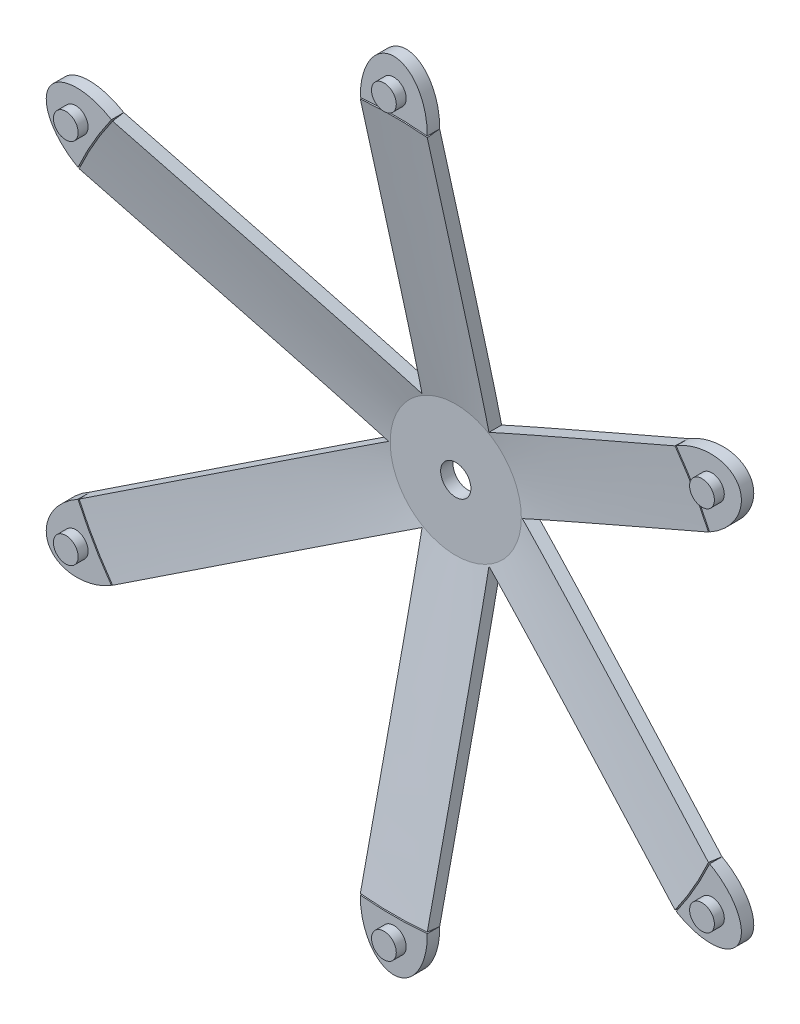
from build123d import *

# Parameters (mm, degrees)
F_6_1_6_1_DIAMETER_HOLE1_D = 6.1
CUT_EXTRUDE6_DEPTH         = 16
BOSS_EXTRUDE1_DEPTH        = 2.5
BOSS_EXTRUDE1_2_DEPTH      = 2.5
BOSS_EXTRUDE1_3_DEPTH      = 2.5
BOSS_EXTRUDE1_4_DEPTH      = 2.5
BOSS_EXTRUDE1_5_DEPTH      = 2.5
BOSS_EXTRUDE1_6_DEPTH      = 2.5
SKETCH8_R                  = 2.5
BOSS_EXTRUDE2_DEPTH        = 2


with BuildPart() as part:
    # Sketch1 → Revolve1 (revolve)
    with BuildSketch(Plane(origin=(0, 0, 0), x_dir=(1, 0, 0), z_dir=(0, 1, 0))):
        Polygon((0, 15), (13.5, 15), (70, 2.5), (69.726754993, 0), (13.226754993, 12.5), (0, 12.5), align=None)
    revolve(axis=Axis((0, 0, -12.5), (0, 0, -1)))

    # Ø6.1 (6.1) Diameter Hole1 (through all)
    with Locations(Plane(origin=(0, 0, -15), x_dir=(-1, 0, 0), z_dir=(0, 0, -1))):
        with Locations((0, 0)):
            Hole(F_6_1_6_1_DIAMETER_HOLE1_D / 2)

    # Sketch6 → Cut-Extrude6 (cut, through all)
    with BuildSketch(Plane.XY):
        with BuildLine():
            Line((6.75, 11.691342951), (6.75, 69.673793495))
            ThreePointArc((6.75, 69.673793495), (35, 60.621778265), (56.964275145, 40.682568223))
            Line((56.964275145, 40.682568223), (6.75, 11.691342951))
        make_face()
        with BuildLine():
            Line((13.5, 0), (63.714275145, 28.991225272))
            ThreePointArc((63.714275145, 28.991225272), (69.046745107, 11.512905374), (69.673793495, -6.75))
            ThreePointArc((69.673793495, -6.75), (67.61480784, -18.117333157), (63.714275145, -28.991225272))
            Line((63.714275145, -28.991225272), (13.5, 0))
        make_face()
        with BuildLine():
            Line((-6.75, 11.691342951), (-6.75, 69.673793495))
            ThreePointArc((-6.75, 69.673793495), (-35, 60.621778265), (-56.964275145, 40.682568223))
            Line((-56.964275145, 40.682568223), (-6.75, 11.691342951))
        make_face()
        with BuildLine():
            Line((6.75, -11.691342951), (56.964275145, -40.682568223))
            ThreePointArc((56.964275145, -40.682568223), (35, -60.621778265), (6.75, -69.673793495))
            Line((6.75, -69.673793495), (6.75, -11.691342951))
        make_face()
        with BuildLine():
            Line((-6.75, -11.691342951), (-6.75, -69.673793495))
            ThreePointArc((-6.75, -69.673793495), (-35, -60.621778265), (-56.964275145, -40.682568223))
            Line((-56.964275145, -40.682568223), (-6.75, -11.691342951))
        make_face()
        with BuildLine():
            Line((-13.5, 0), (-63.714275145, -28.991225272))
            ThreePointArc((-63.714275145, -28.991225272), (-67.61480784, -18.117333157), (-69.673793495, -6.75))
            ThreePointArc((-69.673793495, -6.75), (-69.046745107, 11.512905374), (-63.714275145, 28.991225272))
            Line((-63.714275145, 28.991225272), (-13.5, 0))
        make_face()
    extrude(amount=-CUT_EXTRUDE6_DEPTH, mode=Mode.SUBTRACT)


with BuildPart() as body_2:
    # Sketch7 → Boss-Extrude1 (new body)
    with BuildSketch(Plane.XY):
        with BuildLine():
            ThreePointArc((6.746587752, 69.67412399), (0, 70), (-6.746587752, 69.67412399))
            add(Edge.make_bspline(
                [(6.746587752, 69.67412399), (6.968123789, 80.25), (0, 80.25), (-6.968123789, 80.25), (-6.746587752, 69.67412399)],
                knots=[1.538998187, 1.538998187, 1.538998187, 3.141592654, 3.141592654, 4.74418712, 4.74418712, 4.74418712], degree=2, weights=[1, 0.695775545, 1, 0.695775545, 1]))
        make_face()
    extrude(amount=-BOSS_EXTRUDE1_DEPTH)



with BuildPart() as body_3:
    # Sketch7 → Boss-Extrude1 2 (new body)
    with BuildSketch(Plane.XY):
        with BuildLine():
            ThreePointArc((63.712855237, 28.994345613), (60.621778265, 35), (56.966267485, 40.679778377))
            add(Edge.make_bspline(
                [(63.712855237, 28.994345613), (72.982600548, 34.090427782), (69.498538654, 40.125), (66.014476759, 46.159572218), (56.966267485, 40.679778377)],
                knots=[1.538998187, 1.538998187, 1.538998187, 3.141592654, 3.141592654, 4.74418712, 4.74418712, 4.74418712], degree=2, weights=[1, 0.695775545, 1, 0.695775545, 1]))
        make_face()
    extrude(amount=-BOSS_EXTRUDE1_2_DEPTH)


with BuildPart() as body_4:
    # Sketch7 → Boss-Extrude1 3 (new body)
    with BuildSketch(Plane.XY):
        with BuildLine():
            ThreePointArc((56.966267485, -40.679778377), (60.621778265, -35), (63.712855237, -28.994345613))
            add(Edge.make_bspline(
                [(56.966267485, -40.679778377), (66.014476759, -46.159572218), (69.498538654, -40.125), (72.982600548, -34.090427782), (63.712855237, -28.994345613)],
                knots=[1.538998187, 1.538998187, 1.538998187, 3.141592654, 3.141592654, 4.74418712, 4.74418712, 4.74418712], degree=2, weights=[1, 0.695775545, 1, 0.695775545, 1]))
        make_face()
    extrude(amount=-BOSS_EXTRUDE1_3_DEPTH)


with BuildPart() as body_5:
    # Sketch7 → Boss-Extrude1 4 (new body)
    with BuildSketch(Plane.XY):
        with BuildLine():
            ThreePointArc((-6.746587752, -69.67412399), (0, -70), (6.746587752, -69.67412399))
            add(Edge.make_bspline(
                [(-6.746587752, -69.67412399), (-6.968123789, -80.25), (0, -80.25), (6.968123789, -80.25), (6.746587752, -69.67412399)],
                knots=[1.538998187, 1.538998187, 1.538998187, 3.141592654, 3.141592654, 4.74418712, 4.74418712, 4.74418712], degree=2, weights=[1, 0.695775545, 1, 0.695775545, 1]))
        make_face()
    extrude(amount=-BOSS_EXTRUDE1_4_DEPTH)


with BuildPart() as body_6:
    # Sketch7 → Boss-Extrude1 5 (new body)
    with BuildSketch(Plane.XY):
        with BuildLine():
            ThreePointArc((-63.712855237, -28.994345613), (-60.621778265, -35), (-56.966267485, -40.679778377))
            add(Edge.make_bspline(
                [(-63.712855237, -28.994345613), (-72.982600548, -34.090427782), (-69.498538654, -40.125), (-66.014476759, -46.159572218), (-56.966267485, -40.679778377)],
                knots=[1.538998187, 1.538998187, 1.538998187, 3.141592654, 3.141592654, 4.74418712, 4.74418712, 4.74418712], degree=2, weights=[1, 0.695775545, 1, 0.695775545, 1]))
        make_face()
    extrude(amount=-BOSS_EXTRUDE1_5_DEPTH)


with BuildPart() as body_7:
    # Sketch7 → Boss-Extrude1 6 (new body)
    with BuildSketch(Plane.XY):
        with BuildLine():
            ThreePointArc((-56.966267485, 40.679778377), (-60.621778265, 35), (-63.712855237, 28.994345613))
            add(Edge.make_bspline(
                [(-56.966267485, 40.679778377), (-66.014476759, 46.159572218), (-69.498538654, 40.125), (-72.982600548, 34.090427782), (-63.712855237, 28.994345613)],
                knots=[1.538998187, 1.538998187, 1.538998187, 3.141592654, 3.141592654, 4.74418712, 4.74418712, 4.74418712], degree=2, weights=[1, 0.695775545, 1, 0.695775545, 1]))
        make_face()
    extrude(amount=-BOSS_EXTRUDE1_6_DEPTH)


with BuildPart() as body_2_1:
    add(body_2.part)

    add(body_3.part)  # Boss-Extrude2 merges body 3

    add(body_4.part)  # Boss-Extrude2 merges body 4

    add(body_5.part)  # Boss-Extrude2 merges body 5

    add(body_6.part)  # Boss-Extrude2 merges body 6

    add(body_7.part)  # Boss-Extrude2 merges body 7
    # Sketch8 → Boss-Extrude2 (add)
    with BuildSketch(Plane.XY):
        with Locations((0, 74.0988925)):
            Circle(SKETCH8_R)
        with Locations((64.171523297, 37.04944625)):
            Circle(SKETCH8_R)
        with Locations((64.171523297, -37.04944625)):
            Circle(SKETCH8_R)
        with Locations((0, -74.0988925)):
            Circle(SKETCH8_R)
        with Locations((-64.171523297, -37.04944625)):
            Circle(SKETCH8_R)
        with Locations((-64.171523297, 37.04944625)):
            Circle(SKETCH8_R)
    extrude(amount=BOSS_EXTRUDE2_DEPTH)


solid = Compound([part.part, body_2_1.part])
